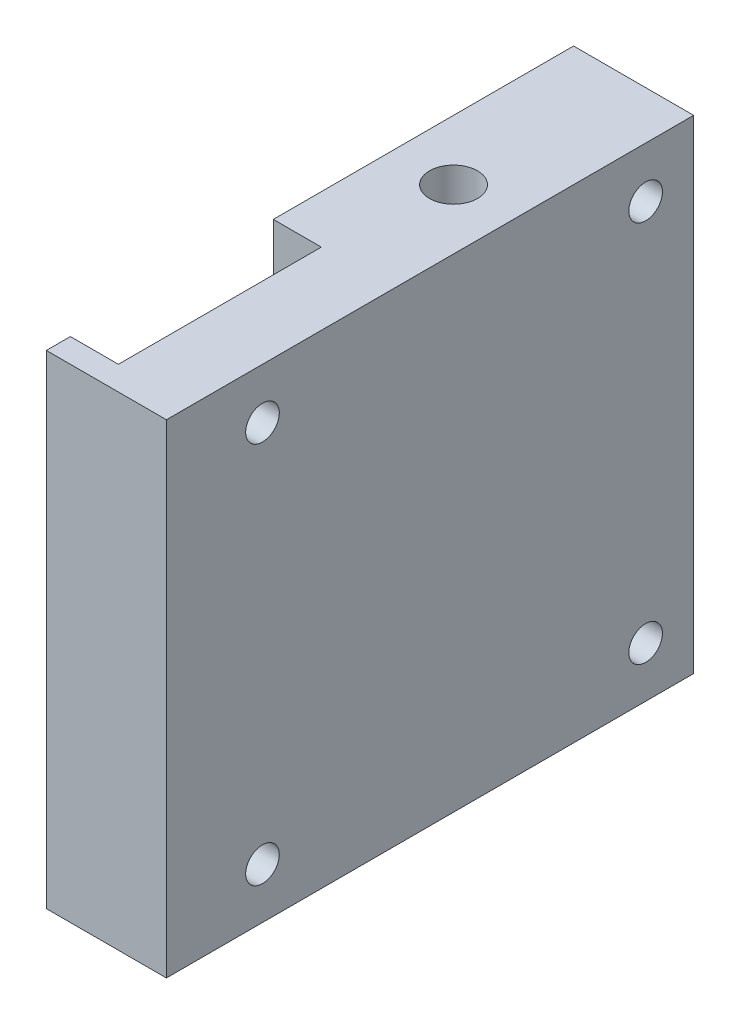
from build123d import *

# Parameters (mm, degrees)
SKETCH2_W           = 39.908935046
SKETCH2_H           = 40.262877017
SKETCH2_R           = 1.4
BOSS_EXTRUDE1_DEPTH = 10
SKETCH5_R           = 3
CUT_EXTRUDE1_DEPTH  = 4
SKETCH6_W           = 14.9
SKETCH6_H           = 30
CUT_EXTRUDE2_DEPTH  = 4
SKETCH9_W           = 10
SKETCH9_H           = 40.262877017
BOSS_EXTRUDE3_DEPTH = 4
SKETCH10_W          = 2
SKETCH10_H          = 30
CUT_EXTRUDE4_DEPTH  = 4
SKETCH11_R          = 2
CUT_EXTRUDE5_DEPTH  = 6


with BuildPart() as part:
    # Sketch2 → Boss-Extrude1 (new body)
    with BuildSketch(Plane.ZY.offset(-34.473625965)):
        with Locations((281.744986803, 328.260975238)):
            Rectangle(SKETCH2_W, SKETCH2_H)
        with Locations((297.699454326, 344.184836729)):
            Circle(SKETCH2_R, mode=Mode.SUBTRACT)
        with Locations((297.699454326, 312.337113746)):
            Circle(SKETCH2_R, mode=Mode.SUBTRACT)
        with Locations((265.79051928, 312.337113746)):
            Circle(SKETCH2_R, mode=Mode.SUBTRACT)
        with Locations((265.79051928, 344.184836729)):
            Circle(SKETCH2_R, mode=Mode.SUBTRACT)
    extrude(amount=BOSS_EXTRUDE1_DEPTH)

    # Sketch5 → Cut-Extrude1 (cut)
    with BuildSketch(Plane.ZY.offset(-24.473625965)):
        with Locations((297.699454326, 344.074881585)):
            Circle(SKETCH5_R)
        with Locations((265.79051928, 312.337113746)):
            Circle(SKETCH5_R)
        with Locations((297.699454326, 312.337113746)):
            Circle(SKETCH5_R)
        with Locations((265.79051928, 344.184836729)):
            Circle(SKETCH5_R)
    extrude(amount=-CUT_EXTRUDE1_DEPTH, mode=Mode.SUBTRACT)

    # Sketch6 → Cut-Extrude2 (cut)
    with BuildSketch(Plane.ZY.offset(-24.473625965)):
        with Locations((294.249454326, 333.392413746)):
            Rectangle(SKETCH6_W, SKETCH6_H)
    extrude(amount=-CUT_EXTRUDE2_DEPTH, mode=Mode.SUBTRACT)

    # Sketch9 → Boss-Extrude3 (add)
    with BuildSketch(Plane.XY.offset(301.699454326)):
        with Locations((29.473625965, 328.260975238)):
            Rectangle(SKETCH9_W, SKETCH9_H)
    extrude(amount=BOSS_EXTRUDE3_DEPTH)

    # Sketch10 → Cut-Extrude4 (cut)
    with BuildSketch(Plane.ZY.offset(-24.473625965)):
        with Locations((302.699454326, 333.392413746)):
            Rectangle(SKETCH10_W, SKETCH10_H)
    extrude(amount=-CUT_EXTRUDE4_DEPTH, mode=Mode.SUBTRACT)

    # Sketch11 → Cut-Extrude5 (cut)
    with BuildSketch(Plane(origin=(0, 348.392413746, 0), x_dir=(1, 0, 0), z_dir=(0, 1, 0))):
        with Locations((29.473625965, -276.79051928)):
            Circle(SKETCH11_R)
    extrude(amount=-CUT_EXTRUDE5_DEPTH, mode=Mode.SUBTRACT)


solid = part.part
